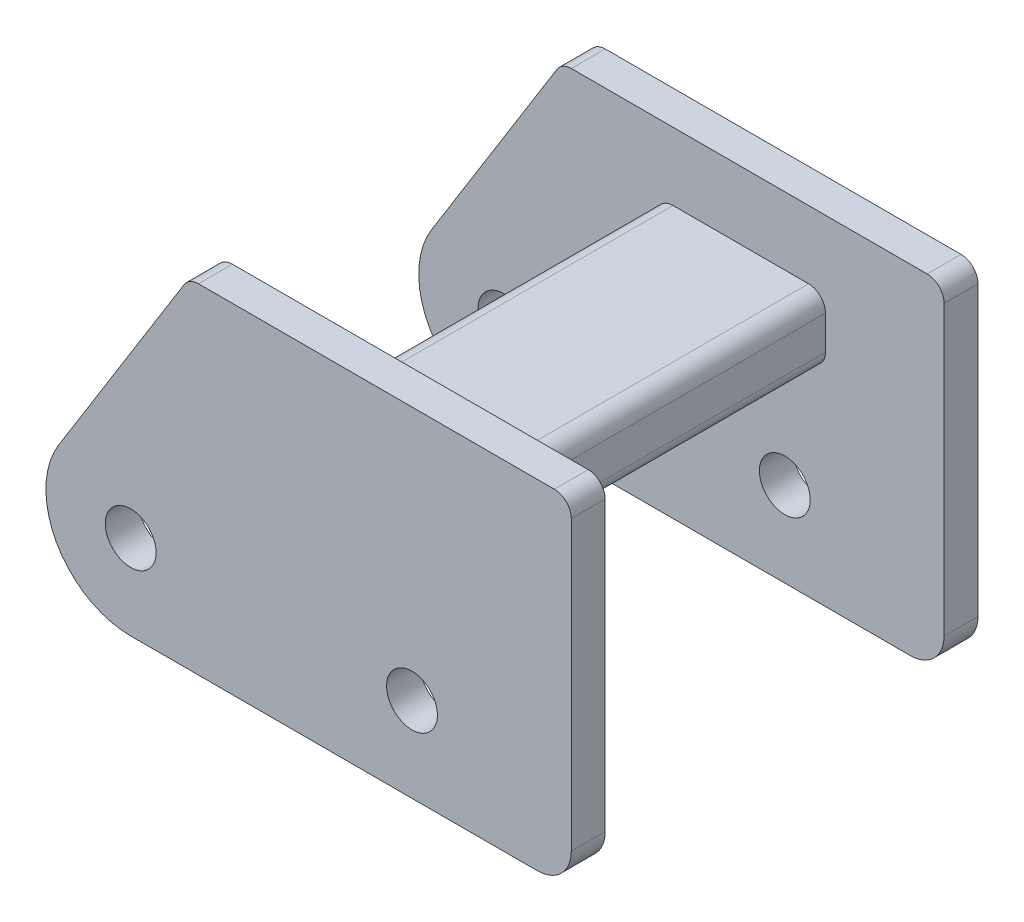
from build123d import *

# Parameters (mm, degrees)
SKETCH1_R           = 0.75
BOSS_EXTRUDE1_DEPTH = 1
BOSS_EXTRUDE2_START = 1
BOSS_EXTRUDE2_DEPTH = 10
BOSS_EXTRUDE3_START = 11
SKETCH1_4_R         = 0.75
BOSS_EXTRUDE3_DEPTH = 1


with BuildPart() as part:
    # Sketch1 → Boss-Extrude1 (new body)
    with BuildSketch(Plane.XY):
        with BuildLine():
            Line((1.575471698, 7.264150943), (-2.122641509, 1.320754717))
            ThreePointArc((-2.122641509, 1.320754717), (-2.18539319, -1.214107328), (0, -2.5))
            Line((0, -2.5), (12, -2.5))
            ThreePointArc((12, -2.5), (12.707106781, -2.207106781), (13, -1.5))
            Line((13, -1.5), (13, 7))
            ThreePointArc((13, 7), (12.853553391, 7.353553391), (12.5, 7.5))
            Line((12.5, 7.5), (2, 7.5))
            ThreePointArc((2, 7.5), (1.757178534, 7.437078638), (1.575471698, 7.264150943))
        make_face()
        Circle(SKETCH1_R, mode=Mode.SUBTRACT)
        with Locations((8.3, 0)):
            Circle(SKETCH1_R, mode=Mode.SUBTRACT)
    extrude(amount=BOSS_EXTRUDE1_DEPTH)

    # Sketch1_3 → Boss-Extrude2 (add)
    with BuildSketch(Plane.XY.offset(BOSS_EXTRUDE2_START)):
        with BuildLine():
            Line((5, 5.5), (9, 5.5))
            ThreePointArc((9, 5.5), (9.353553391, 5.353553391), (9.5, 5))
            Line((9.5, 5), (9.5, 4))
            ThreePointArc((9.5, 4), (9.353553391, 3.646446609), (9, 3.5))
            Line((9, 3.5), (5, 3.5))
            ThreePointArc((5, 3.5), (4.646446609, 3.646446609), (4.5, 4))
            Line((4.5, 4), (4.5, 5))
            ThreePointArc((4.5, 5), (4.646446609, 5.353553391), (5, 5.5))
        make_face()
    extrude(amount=BOSS_EXTRUDE2_DEPTH)

    # Sketch1_4 → Boss-Extrude3 (add)
    with BuildSketch(Plane.XY.offset(BOSS_EXTRUDE3_START)):
        with BuildLine():
            Line((1.575471698, 7.264150943), (-2.122641509, 1.320754717))
            ThreePointArc((-2.122641509, 1.320754717), (-2.18539319, -1.214107328), (0, -2.5))
            Line((0, -2.5), (12, -2.5))
            ThreePointArc((12, -2.5), (12.707106781, -2.207106781), (13, -1.5))
            Line((13, -1.5), (13, 7))
            ThreePointArc((13, 7), (12.853553391, 7.353553391), (12.5, 7.5))
            Line((12.5, 7.5), (2, 7.5))
            ThreePointArc((2, 7.5), (1.757178534, 7.437078638), (1.575471698, 7.264150943))
        make_face()
        Circle(SKETCH1_4_R, mode=Mode.SUBTRACT)
        with Locations((8.3, 0)):
            Circle(SKETCH1_4_R, mode=Mode.SUBTRACT)
    extrude(amount=BOSS_EXTRUDE3_DEPTH)


solid = part.part
